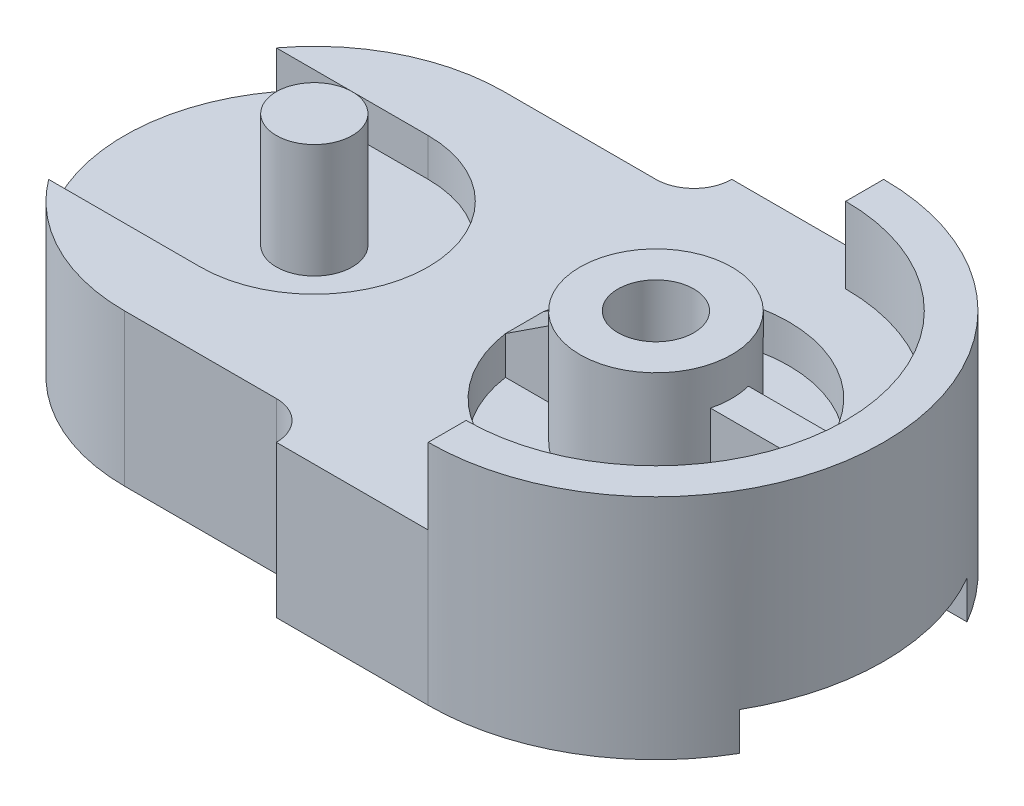
from build123d import *

# Parameters (mm, degrees)
SKETCH1_W                 = 200
SKETCH1_H                 = 120
BOSS_EXTRUDE1_DEPTH       = 40
CUT_EXTRUDE2_DEPTH        = 40
CUT_EXTRUDE3_DEPTH        = 40
CUT_EXTRUDE4_DEPTH        = 40
SKETCH5_W                 = 208.7299617
SKETCH5_H                 = 60
CUT_EXTRUDE5_DEPTH        = 10
CUT_EXTRUDE6_DEPTH        = 116
BOSS_EXTRUDE2_DEPTH       = 20
CUT_EXTRUDE7_DEPTH        = 10
SKETCH9_R                 = 10
BOSS_EXTRUDE3_DEPTH       = 30
SKETCH10_R                = 10
CUT_EXTRUDE8_DEPTH        = 69
SKETCH11_R                = 20
SKETCH11_R_2              = 10
BOSS_EXTRUDE4_DEPTH       = 20
SKETCH12_R                = 35
SKETCH12_R_2              = 20
CUT_EXTRUDE9_DEPTH        = 10
BOSS_EXTRUDE10_DEPTH      = 10
BOSS_EXTRUDE10_DEPTH_BACK = 36
BOSS_EXTRUDE11_DEPTH      = 20
CUT_EXTRUDE10_DEPTH       = 20
SKETCH17_W                = 10
SKETCH17_H                = 10
CUT_EXTRUDE11_DEPTH       = 20
SKETCH18_W                = 181.961524227
SKETCH18_H                = 60
CUT_EXTRUDE12_DEPTH       = 20


with BuildPart() as part:
    # Sketch1 → Boss-Extrude1 (new body)
    with BuildSketch(Plane(origin=(0, 0, 0), x_dir=(1, 0, 0), z_dir=(0, 1, 0))):
        with Locations((100, 60)):
            Rectangle(SKETCH1_W, SKETCH1_H)
    extrude(amount=BOSS_EXTRUDE1_DEPTH)

    # Sketch2 → Cut-Extrude2 (cut)
    with BuildSketch(Plane(origin=(0, 40, 0), x_dir=(1, 0, 0), z_dir=(0, 1, 0))):
        Polygon((0, 110), (50, 110), (90, 110), (90, 120), (0, 120), align=None)
        with BuildLine():
            ThreePointArc((0, 60), (14.644660941, 95.355339059), (50, 110))
            Line((50, 110), (0, 110))
            Line((0, 110), (0, 60))
        make_face()
        with BuildLine():
            ThreePointArc((50, 10), (14.644660941, 24.644660941), (0, 60))
            Line((0, 60), (0, 0))
            Line((0, 0), (90, 0))
            Line((90, 0), (90, 10))
            Line((90, 10), (50, 10))
        make_face()
    extrude(amount=-CUT_EXTRUDE2_DEPTH, mode=Mode.SUBTRACT)

    # Sketch3 → Cut-Extrude3 (cut)
    with BuildSketch(Plane(origin=(0, 40, 0), x_dir=(1, 0, 0), z_dir=(0, 1, 0))):
        with BuildLine():
            Line((90, 110), (90, 120))
            Line((90, 120), (100, 120))
            ThreePointArc((100, 120), (97.071067812, 112.928932188), (90, 110))
        make_face()
    extrude(amount=-CUT_EXTRUDE3_DEPTH, mode=Mode.SUBTRACT)

    # Sketch4 → Cut-Extrude4 (cut)
    with BuildSketch(Plane(origin=(0, 40, 0), x_dir=(1, 0, 0), z_dir=(0, 1, 0))):
        with BuildLine():
            Line((90, 10), (90, 0))
            Line((90, 0), (100, 0))
            ThreePointArc((100, 0), (97.071067812, 7.071067812), (90, 10))
        make_face()
    extrude(amount=-CUT_EXTRUDE4_DEPTH, mode=Mode.SUBTRACT)

    # Sketch5 → Cut-Extrude5 (cut)
    with BuildSketch(Plane.XZ):
        with Locations((95.63501915, -60)):
            Rectangle(SKETCH5_W, SKETCH5_H)
    extrude(amount=-CUT_EXTRUDE5_DEPTH, mode=Mode.SUBTRACT)

    # Sketch6 → Cut-Extrude6 (cut)
    with BuildSketch(Plane(origin=(0, 40, 0), x_dir=(1, 0, 0), z_dir=(0, 1, 0))):
        with BuildLine():
            Line((200, 120), (140, 120))
            ThreePointArc((140, 120), (182.426406871, 102.426406871), (200, 60))
            Line((200, 60), (200, 120))
        make_face()
        with BuildLine():
            Line((200, 0), (200, 60))
            ThreePointArc((200, 60), (182.426406871, 17.573593129), (140, 0))
            Line((140, 0), (200, 0))
        make_face()
    extrude(amount=-CUT_EXTRUDE6_DEPTH, mode=Mode.SUBTRACT)

    # Sketch7 → Boss-Extrude2 (add)
    with BuildSketch(Plane(origin=(0, 40, 0), x_dir=(1, 0, 0), z_dir=(0, 1, 0))):
        with BuildLine():
            Line((140, 110), (140, 120))
            ThreePointArc((140, 120), (200, 60), (140, 0))
            Line((140, 0), (140, 10))
            ThreePointArc((140, 10), (190, 60), (140, 110))
        make_face()
    extrude(amount=BOSS_EXTRUDE2_DEPTH)

    # Sketch8 → Cut-Extrude7 (cut)
    with BuildSketch(Plane(origin=(0, 40, 0), x_dir=(1, 0, 0), z_dir=(0, 1, 0))):
        with BuildLine():
            Line((50, 90), (10, 90))
            ThreePointArc((10, 90), (0, 60), (10, 30))
            Line((10, 30), (50, 30))
            ThreePointArc((50, 30), (80, 60), (50, 90))
        make_face()
    extrude(amount=-CUT_EXTRUDE7_DEPTH, mode=Mode.SUBTRACT)

    # Sketch9 → Boss-Extrude3 (add)
    with BuildSketch(Plane(origin=(0, 30, 0), x_dir=(1, 0, 0), z_dir=(0, 1, 0))):
        with Locations((50, 60)):
            Circle(SKETCH9_R)
    extrude(amount=BOSS_EXTRUDE3_DEPTH)

    # Sketch10 → Cut-Extrude8 (cut)
    with BuildSketch(Plane(origin=(0, 40, 0), x_dir=(1, 0, 0), z_dir=(0, 1, 0))):
        with Locations((140, 60)):
            Circle(SKETCH10_R)
    extrude(amount=-CUT_EXTRUDE8_DEPTH, mode=Mode.SUBTRACT)

    # Sketch11 → Boss-Extrude4 (add)
    with BuildSketch(Plane(origin=(0, 40, 0), x_dir=(1, 0, 0), z_dir=(0, 1, 0))):
        with Locations((140, 60)):
            Circle(SKETCH11_R)
        with Locations((140, 60)):
            Circle(SKETCH11_R_2, mode=Mode.SUBTRACT)
    extrude(amount=BOSS_EXTRUDE4_DEPTH)

    # Sketch12 → Cut-Extrude9 (cut)
    with BuildSketch(Plane(origin=(0, 40, 0), x_dir=(1, 0, 0), z_dir=(0, 1, 0))):
        with Locations((140, 60)):
            Circle(SKETCH12_R)
        with Locations((140, 60)):
            Circle(SKETCH12_R_2, mode=Mode.SUBTRACT)
    extrude(amount=-CUT_EXTRUDE9_DEPTH, mode=Mode.SUBTRACT)

    # Sketch14 → Boss-Extrude10 (add, two sides)
    with BuildSketch(Plane(origin=(0, 40, 0), x_dir=(1, 0, 0), z_dir=(0, 1, 0))) as boss_extrude10_sk:
        with BuildLine():
            Line((174.641016151, 65), (160, 65))
            Line((160, 65), (160, 55))
            Line((160, 55), (174.641016151, 55))
            ThreePointArc((174.641016151, 55), (174.91013868, 57.493564812), (175, 60))
            ThreePointArc((175, 60), (174.91013868, 62.506435188), (174.641016151, 65))
        make_face()
        with BuildLine():
            Line((158.948525297, 65), (160, 65))
            Line((160, 65), (160, 55))
            Line((160, 55), (158.948525297, 55))
            ThreePointArc((158.948525297, 55), (159.597107209, 60), (158.948525297, 65))
        make_face()
        with BuildLine():
            Line((189.749371855, 65), (174.641016151, 65))
            ThreePointArc((174.641016151, 65), (174.91013868, 62.506435188), (175, 60))
            ThreePointArc((175, 60), (174.91013868, 57.493564812), (174.641016151, 55))
            Line((174.641016151, 55), (189.749371855, 55))
            ThreePointArc((189.749371855, 55), (190, 60), (189.749371855, 65))
        make_face()
    extrude(amount=BOSS_EXTRUDE10_DEPTH)
    extrude(boss_extrude10_sk.sketch, amount=-BOSS_EXTRUDE10_DEPTH_BACK)

    # Sketch15 → Boss-Extrude11 (add)
    with BuildSketch(Plane(origin=(0, 30, 0), x_dir=(1, 0, 0), z_dir=(0, 1, 0))):
        with BuildLine():
            Line((120.635083269, 55), (120.635083269, 65))
            ThreePointArc((120.635083269, 65), (120, 60), (120.635083269, 55))
        make_face()
        with BuildLine():
            ThreePointArc((120.635083269, 55), (120, 60), (120.635083269, 65))
            Line((120.635083269, 65), (105.358983849, 65))
            ThreePointArc((105.358983849, 65), (105, 60), (105.358983849, 55))
            Line((105.358983849, 55), (120.635083269, 55))
        make_face()
    extrude(amount=BOSS_EXTRUDE11_DEPTH)

    # Sketch16 → Cut-Extrude10 (cut)
    with BuildSketch(Plane.XY.offset(-55)):
        Polygon((120.635083269, 50), (105.358983849, 40), (105.358983849, 50), align=None)
    extrude(amount=-CUT_EXTRUDE10_DEPTH, mode=Mode.SUBTRACT)

    # Sketch17 → Cut-Extrude11 (cut)
    with BuildSketch(Plane(origin=(105.358983849, 0, 0), x_dir=(0, 0, -1), z_dir=(1, 0, 0))):
        with Locations((60, 45)):
            Rectangle(SKETCH17_W, SKETCH17_H)
    extrude(amount=-CUT_EXTRUDE11_DEPTH, mode=Mode.SUBTRACT)

    # Sketch18 → Cut-Extrude12 (cut)
    with BuildSketch(Plane.XZ.offset(-10)):
        with Locations((100.980762114, -60)):
            Rectangle(SKETCH18_W, SKETCH18_H)
    extrude(amount=CUT_EXTRUDE12_DEPTH, mode=Mode.SUBTRACT)


solid = part.part
